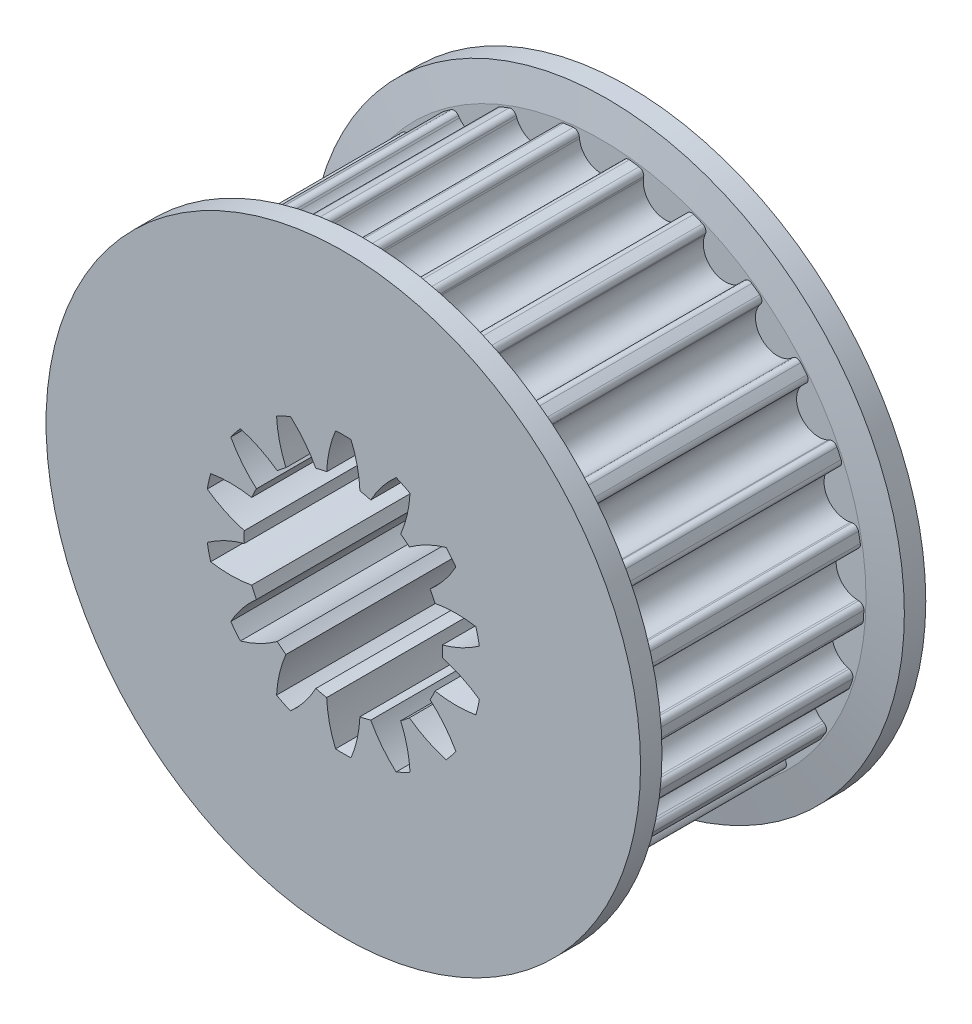
from build123d import *

# Parameters (mm, degrees)
SKETCH2_R                                 = 19.346824389
PULLEY_DEPTH                              = 8.5
CUT_TOOTH_DEPTH                           = 8.5
BLEND_TOOTH_R                             = 0.4
TOOTH_PATTERN_COUNT                       = 25
BLEND_TOOTH_OF_TOOTH_PATTERN_R            = 0.4
SIDEWALL_START                            = 8.5
SKETCH3_R                                 = 21.886824389
SIDEWALL_DEPTH                            = 2
SIDEWALL_CHAMFER_SIZE                     = 2.4
SIDEWALL_CHAMFER_SIZE2                    = 0.423184754
SIDEWALL_CHAMFER_PART_2_SIZE              = 2.4
SIDEWALL_CHAMFER_PART_2_SIZE2             = 0.423184754
SKETCH5_R                                 = 9.525
BEARING_SPACER_MANUAL_SUPPRESS_DEPTH      = 10.55
BEARING_SPACER_MANUAL_SUPPRESS_DEPTH_BACK = 10.55
CUT_EXTRUDE1_DEPTH                        = 1.05
CUT_EXTRUDE1_DEPTH_BACK                   = 22.05
SKETCH7_W                                 = 28.567274034
SKETCH7_H                                 = 23.850528381
SKETCH7_W_2                               = 31.733322646
SKETCH7_H_2                               = 22.012307779
CUT_EXTRUDE2_DEPTH                        = 22.886824389
CUT_EXTRUDE2_DEPTH_BACK                   = 22.886824389


with BuildPart() as part:
    # Sketch2 → pulley (new body, symmetric)
    with BuildSketch(Plane.XY):
        Circle(SKETCH2_R)
    extrude(amount=PULLEY_DEPTH, both=True)

    # tooth → cut tooth (cut, symmetric)
    with BuildSketch(Plane.XY):
        with BuildLine():
            Line((-2.132711892, 22.982416669), (-1.612887496, 18.748786706))
            ThreePointArc((-1.612887496, 18.748786706), (0, 17.321824389), (1.612887496, 18.748786706))
            Line((1.612887496, 18.748786706), (2.132711892, 22.982416669))
            Line((2.132711892, 22.982416669), (-2.132711892, 22.982416669))
        make_face()
    cut_tooth = extrude(amount=CUT_TOOTH_DEPTH, both=True, mode=Mode.SUBTRACT)

    # blend tooth
    blend_tooth_edges = [part.edges().sort_by_distance(p)[0] for p in [
        (1.677372268, 19.273973026, 0),
        (-1.677372268, 19.273973026, 0),
    ]]
    fillet(blend_tooth_edges, radius=BLEND_TOOTH_R)

    # tooth pattern: cut tooth ×25 about axis
    tooth_pattern_axis = Axis((0, 0, 0), (0, 0, 1))
    for i in range(1, TOOTH_PATTERN_COUNT):
        add(cut_tooth.rotate(tooth_pattern_axis, i * 360 / TOOTH_PATTERN_COUNT), mode=Mode.SUBTRACT)

    # blend tooth of tooth pattern
    blend_tooth_of_tooth_pattern_edges = [part.edges().sort_by_distance(p)[0] for p in [
        (-3.168567643, 19.085591241, 0),
        (-6.417916711, 18.251300201, 0),
        (-7.815414796, 17.697991567, 0),
        (-10.755199843, 16.081831061, 0),
        (-11.971190695, 15.198361993, 0),
        (-14.416694215, 12.90188133, 0),
        (-15.374772655, 11.743763441, 0),
        (-17.172334668, 8.911258946, 0),
        (-17.812301105, 7.55126104, 0),
        (-18.848974178, 4.360709388, 0),
        (-19.130617167, 2.884285137, 0),
        (-19.341263319, -0.463839577, 0),
        (-19.246886195, -1.963921009, 0),
        (-18.618269754, -5.259243797, 0),
        (-18.153802578, -6.688726775, 0),
        (-16.725421826, -9.724190386, 0),
        (-15.920048781, -10.993255239, 0),
        (-13.781654134, -13.57813033, 0),
        (-12.685979769, -14.607037045, 0),
        (-9.971934427, -16.578906409, 0),
        (-8.654803992, -17.303004993, 0),
        (-5.535641406, -18.537968825, 0),
        (-4.07981505, -18.911761502, 0),
        (-0.751523676, -19.332222482, 0),
        (0.751523676, -19.332222482, 0),
        (4.07981505, -18.911761502, 0),
        (5.535641406, -18.537968825, 0),
        (8.654803992, -17.303004993, 0),
        (9.971934427, -16.578906409, 0),
        (12.685979769, -14.607037045, 0),
        (13.781654134, -13.57813033, 0),
        (15.920048781, -10.993255239, 0),
        (16.725421826, -9.724190386, 0),
        (18.153802578, -6.688726775, 0),
        (18.618269754, -5.259243797, 0),
        (19.246886195, -1.963921009, 0),
        (19.341263319, -0.463839577, 0),
        (19.130617167, 2.884285137, 0),
        (18.848974178, 4.360709388, 0),
        (17.812301105, 7.55126104, 0),
        (17.172334668, 8.911258946, 0),
        (15.374772655, 11.743763441, 0),
        (14.416694215, 12.90188133, 0),
        (11.971190695, 15.198361993, 0),
        (10.755199843, 16.081831061, 0),
        (7.815414796, 17.697991567, 0),
        (6.417916711, 18.251300201, 0),
        (3.168567643, 19.085591241, 0),
    ]]
    fillet(blend_tooth_of_tooth_pattern_edges, radius=BLEND_TOOTH_OF_TOOTH_PATTERN_R)

    # Sketch3 → sidewall (add)
    with BuildSketch(Plane.XY.offset(SIDEWALL_START)):
        Circle(SKETCH3_R)
    sidewall = extrude(amount=SIDEWALL_DEPTH)

    # mirror sidewall: sidewall across plane
    add(sidewall.mirror(Plane.XY))

    # sidewall chamfer
    sidewall_chamfer_edges = [part.edges().sort_by_distance(p)[0] for p in [
        (-21.886824389, 0, 8.5),
    ]]
    sidewall_chamfer_side = [part.faces().sort_by_distance(p)[0] for p in [
        (-21.267771511, 0, 8.5),
    ]]
    chamfer(sidewall_chamfer_edges, length=SIDEWALL_CHAMFER_SIZE, length2=SIDEWALL_CHAMFER_SIZE2, reference=sidewall_chamfer_side[0])

    # sidewall chamfer part 2
    sidewall_chamfer_part_2_edges = [part.edges().sort_by_distance(p)[0] for p in [
        (-21.886824389, 0, -8.5),
    ]]
    sidewall_chamfer_part_2_side = [part.faces().sort_by_distance(p)[0] for p in [
        (-21.267771511, 0, -8.5),
    ]]
    chamfer(sidewall_chamfer_part_2_edges, length=SIDEWALL_CHAMFER_PART_2_SIZE, length2=SIDEWALL_CHAMFER_PART_2_SIZE2, reference=sidewall_chamfer_part_2_side[0])

    # Sketch5 → bearing spacer (Manual Suppress) (add, two sides)
    with BuildSketch(Plane.XY) as bearing_spacer_manual_suppress_sk:
        Circle(SKETCH5_R)
    extrude(amount=BEARING_SPACER_MANUAL_SUPPRESS_DEPTH)
    extrude(bearing_spacer_manual_suppress_sk.sketch, amount=-BEARING_SPACER_MANUAL_SUPPRESS_DEPTH_BACK)

    # Sketch6 → Cut-Extrude1 (cut, two sides)
    with BuildSketch(Plane(origin=(0, 0, -10.5), x_dir=(-1, 0, 0), z_dir=(0, 0, -1))) as cut_extrude1_sk:
        with BuildLine():
            ThreePointArc((2.021591322, -7.017098744), (2.850463577, -8.284065014), (3.888063673, -9.38661605))
            ThreePointArc((3.888063673, -9.38661605), (4.408258789, -9.153843698), (4.914583893, -8.892269967))
            ThreePointArc((4.914583893, -8.892269967), (4.69950786, -7.393612219), (4.22574714, -5.955633246))
            ThreePointArc((4.22574714, -5.955633246), (4.553034278, -5.709324401), (4.865995885, -5.445051909))
            ThreePointArc((4.865995885, -5.445051909), (6.162500046, -6.226914882), (7.575724395, -6.770081232))
            ThreePointArc((7.575724395, -6.770081232), (7.943407862, -6.334656387), (8.286098429, -5.879300369))
            ThreePointArc((8.286098429, -5.879300369), (7.442078391, -4.622374388), (6.391319038, -3.532357173))
            ThreePointArc((6.391319038, -3.532357173), (6.579325158, -3.168436005), (6.746630286, -2.794545765))
            ThreePointArc((6.746630286, -2.794545765), (8.253977802, -2.93644789), (9.762919991, -2.812648796))
            ThreePointArc((9.762919991, -2.812648796), (9.905267588, -2.260812689), (10.016449548, -1.701863229))
            ThreePointArc((10.016449548, -1.701863229), (8.710654026, -0.93561862), (7.291011817, -0.409454441))
            ThreePointArc((7.291011817, -0.409454441), (7.3025, 0), (7.291011817, 0.409454441))
            ThreePointArc((7.291011817, 0.409454441), (8.710654026, 0.93561862), (10.016449548, 1.701863229))
            ThreePointArc((10.016449548, 1.701863229), (9.905267588, 2.260812689), (9.762919991, 2.812648796))
            ThreePointArc((9.762919991, 2.812648796), (8.253977802, 2.93644789), (6.746630286, 2.794545765))
            ThreePointArc((6.746630286, 2.794545765), (6.579325158, 3.168436005), (6.391319038, 3.532357173))
            ThreePointArc((6.391319038, 3.532357173), (7.442078391, 4.622374388), (8.286098429, 5.879300369))
            ThreePointArc((8.286098429, 5.879300369), (7.943407862, 6.334656387), (7.575724395, 6.770081232))
            ThreePointArc((7.575724395, 6.770081232), (6.162500046, 6.226914882), (4.865995885, 5.445051909))
            ThreePointArc((4.865995885, 5.445051909), (4.553034278, 5.709324401), (4.22574714, 5.955633246))
            ThreePointArc((4.22574714, 5.955633246), (4.69950786, 7.393612219), (4.914583893, 8.892269967))
            ThreePointArc((4.914583893, 8.892269967), (4.408258789, 9.153843698), (3.888063673, 9.38661605))
            ThreePointArc((3.888063673, 9.38661605), (2.850463577, 8.284065014), (2.021591322, 7.017098744))
            ThreePointArc((2.021591322, 7.017098744), (1.62495912, 7.119411079), (1.223214196, 7.199323113))
            ThreePointArc((1.223214196, 7.199323113), (1.026142161, 8.700454472), (0.569675744, 10.144016441))
            ThreePointArc((0.569675744, 10.144016441), (0, 10.16), (-0.569675744, 10.144016441))
            ThreePointArc((-0.569675744, 10.144016441), (-1.026142161, 8.700454472), (-1.223214196, 7.199323113))
            ThreePointArc((-1.223214196, 7.199323113), (-1.62495912, 7.119411079), (-2.021591322, 7.017098744))
            ThreePointArc((-2.021591322, 7.017098744), (-2.850463577, 8.284065014), (-3.888063673, 9.38661605))
            ThreePointArc((-3.888063673, 9.38661605), (-4.408258789, 9.153843698), (-4.914583893, 8.892269967))
            ThreePointArc((-4.914583893, 8.892269967), (-4.69950786, 7.393612219), (-4.22574714, 5.955633246))
            ThreePointArc((-4.22574714, 5.955633246), (-4.553034278, 5.709324401), (-4.865995885, 5.445051909))
            ThreePointArc((-4.865995885, 5.445051909), (-6.162500046, 6.226914882), (-7.575724395, 6.770081232))
            ThreePointArc((-7.575724395, 6.770081232), (-7.943407862, 6.334656387), (-8.286098429, 5.879300369))
            ThreePointArc((-8.286098429, 5.879300369), (-7.442078391, 4.622374388), (-6.391319038, 3.532357173))
            ThreePointArc((-6.391319038, 3.532357173), (-6.579325158, 3.168436005), (-6.746630286, 2.794545765))
            ThreePointArc((-6.746630286, 2.794545765), (-8.253977802, 2.93644789), (-9.762919991, 2.812648796))
            ThreePointArc((-9.762919991, 2.812648796), (-9.905267588, 2.260812689), (-10.016449548, 1.701863229))
            ThreePointArc((-10.016449548, 1.701863229), (-8.710654026, 0.93561862), (-7.291011817, 0.409454441))
            ThreePointArc((-7.291011817, 0.409454441), (-7.3025, 0), (-7.291011817, -0.409454441))
            ThreePointArc((-7.291011817, -0.409454441), (-8.710654026, -0.93561862), (-10.016449548, -1.701863229))
            ThreePointArc((-10.016449548, -1.701863229), (-9.905267588, -2.260812689), (-9.762919991, -2.812648796))
            ThreePointArc((-9.762919991, -2.812648796), (-8.253977802, -2.93644789), (-6.746630286, -2.794545765))
            ThreePointArc((-6.746630286, -2.794545765), (-6.579325158, -3.168436005), (-6.391319038, -3.532357173))
            ThreePointArc((-6.391319038, -3.532357173), (-7.442078391, -4.622374388), (-8.286098429, -5.879300369))
            ThreePointArc((-8.286098429, -5.879300369), (-7.943407862, -6.334656387), (-7.575724395, -6.770081232))
            ThreePointArc((-7.575724395, -6.770081232), (-6.162500046, -6.226914882), (-4.865995885, -5.445051909))
            ThreePointArc((-4.865995885, -5.445051909), (-4.553034278, -5.709324401), (-4.22574714, -5.955633246))
            ThreePointArc((-4.22574714, -5.955633246), (-4.69950786, -7.393612219), (-4.914583893, -8.892269967))
            ThreePointArc((-4.914583893, -8.892269967), (-4.408258789, -9.153843698), (-3.888063673, -9.38661605))
            ThreePointArc((-3.888063673, -9.38661605), (-2.850463577, -8.284065014), (-2.021591322, -7.017098744))
            ThreePointArc((-2.021591322, -7.017098744), (-1.62495912, -7.119411079), (-1.223214196, -7.199323113))
            ThreePointArc((-1.223214196, -7.199323113), (-1.026142161, -8.700454472), (-0.569675744, -10.144016441))
            ThreePointArc((-0.569675744, -10.144016441), (0, -10.16), (0.569675744, -10.144016441))
            ThreePointArc((0.569675744, -10.144016441), (1.026142161, -8.700454472), (1.223214196, -7.199323113))
            ThreePointArc((1.223214196, -7.199323113), (1.62495912, -7.119411079), (2.021591322, -7.017098744))
        make_face()
    extrude(amount=CUT_EXTRUDE1_DEPTH, mode=Mode.SUBTRACT)
    extrude(cut_extrude1_sk.sketch, amount=-CUT_EXTRUDE1_DEPTH_BACK, mode=Mode.SUBTRACT)

    # Sketch7 → Cut-Extrude2 (cut, two sides)
    with BuildSketch(Plane(origin=(0, 0, 0), x_dir=(1, 0, 0), z_dir=(0, 1, 0))) as cut_extrude2_sk:
        with Locations((0.531806592, -22.425264191)):
            Rectangle(SKETCH7_W, SKETCH7_H)
        with Locations((0.163446122, 21.50615389)):
            Rectangle(SKETCH7_W_2, SKETCH7_H_2)
    extrude(amount=CUT_EXTRUDE2_DEPTH, mode=Mode.SUBTRACT)
    extrude(cut_extrude2_sk.sketch, amount=-CUT_EXTRUDE2_DEPTH_BACK, mode=Mode.SUBTRACT)


solid = part.part
